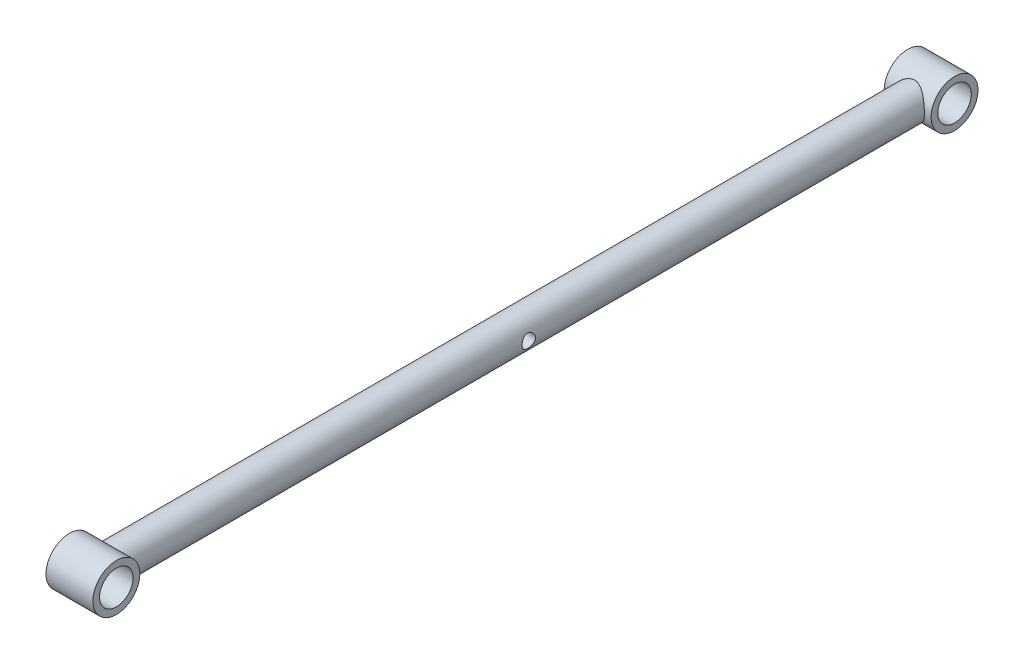
from build123d import *

# Parameters (mm, degrees)
SKETCH1_R           = 12.5
BOSS_EXTRUDE4_DEPTH = 625.3
SKETCH4_R           = 5
CUT_EXTRUDE2_DEPTH  = 312.65
SKETCH5_R           = 17.5
SKETCH5_R_2         = 12.5
BOSS_EXTRUDE6_DEPTH = 17.5
SKETCH7_R           = 12.5
CUT_EXTRUDE4_DEPTH  = 17.5


with BuildPart() as part:
    # Sketch1 → Boss-Extrude4 (new body)
    with BuildSketch(Plane.XY):
        Circle(SKETCH1_R)
    extrude(amount=BOSS_EXTRUDE4_DEPTH)

    # Sketch4 → Cut-Extrude2 (cut, symmetric)
    with BuildSketch(Plane(origin=(0, 0, 0), x_dir=(0, 0, -1), z_dir=(1, 0, 0))):
        with Locations((-312.65, 0)):
            Circle(SKETCH4_R)
    extrude(amount=CUT_EXTRUDE2_DEPTH, both=True, mode=Mode.SUBTRACT)

    # Sketch5 → Boss-Extrude6 (add, symmetric)
    with BuildSketch(Plane(origin=(0, 0, 0), x_dir=(0, 0, -1), z_dir=(1, 0, 0))):
        Circle(SKETCH5_R)
        Circle(SKETCH5_R_2, mode=Mode.SUBTRACT)
        with Locations((-625.3, 0)):
            Circle(SKETCH5_R)
        with Locations((-625.3, 0)):
            Circle(SKETCH5_R_2, mode=Mode.SUBTRACT)
    extrude(amount=BOSS_EXTRUDE6_DEPTH, both=True)

    # Sketch7 → Cut-Extrude4 (cut, symmetric)
    with BuildSketch(Plane(origin=(0, 0, 0), x_dir=(0, 0, -1), z_dir=(1, 0, 0))):
        Circle(SKETCH7_R)
        with Locations((-625.3, 0)):
            Circle(SKETCH7_R)
    extrude(amount=CUT_EXTRUDE4_DEPTH, both=True, mode=Mode.SUBTRACT)


solid = part.part
